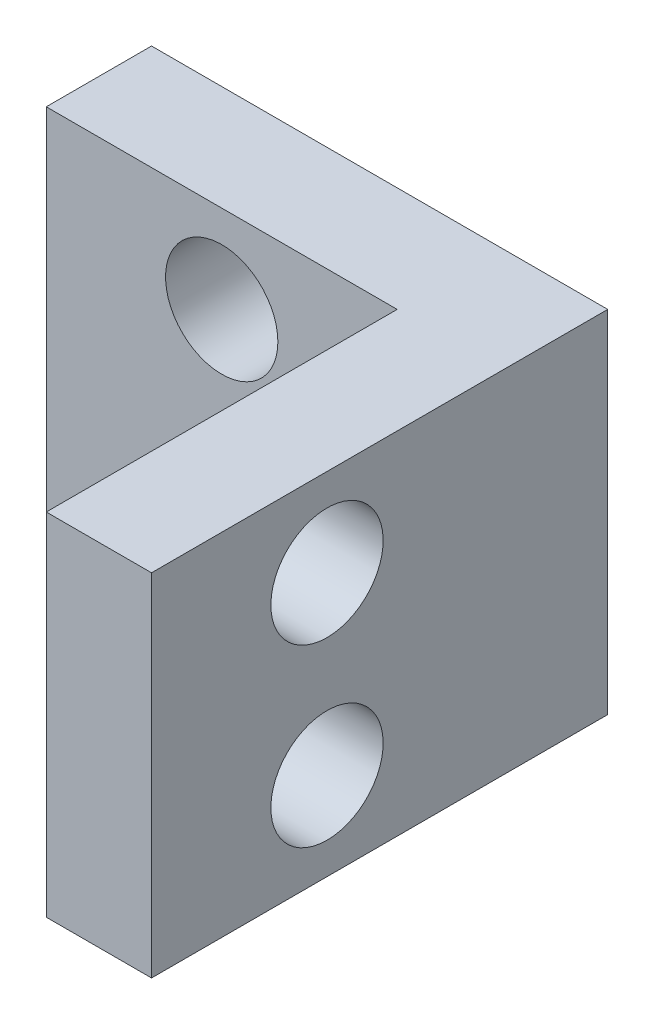
from build123d import *

# Parameters (mm, degrees)
SKETCH1_W           = 10
SKETCH1_H           = 10
BOSS_EXTRUDE1_DEPTH = 3
SKETCH2_W           = 13
SKETCH2_H           = 10
BOSS_EXTRUDE2_DEPTH = 3
SKETCH3_R           = 1.6
CUT_EXTRUDE1_DEPTH  = 4
SKETCH4_R           = 1.6
CUT_EXTRUDE2_DEPTH  = 4


with BuildPart() as part:
    # Sketch1 → Boss-Extrude1 (new body)
    with BuildSketch(Plane.XY):
        with Locations((5, -5)):
            Rectangle(SKETCH1_W, SKETCH1_H)
    extrude(amount=BOSS_EXTRUDE1_DEPTH)

    # Sketch2 → Boss-Extrude2 (add)
    with BuildSketch(Plane(origin=(10, 0, 0), x_dir=(0, 0, -1), z_dir=(1, 0, 0))):
        with Locations((-6.5, -5)):
            Rectangle(SKETCH2_W, SKETCH2_H)
    extrude(amount=BOSS_EXTRUDE2_DEPTH)

    # Sketch3 → Cut-Extrude1 (cut, through all)
    with BuildSketch(Plane.XY.offset(3)):
        with Locations((5, -2.5)):
            Circle(SKETCH3_R)
        with Locations((5, -7.5)):
            Circle(SKETCH3_R)
    extrude(amount=-CUT_EXTRUDE1_DEPTH, mode=Mode.SUBTRACT)

    # Sketch4 → Cut-Extrude2 (cut, through all)
    with BuildSketch(Plane.ZY.offset(-10)):
        with Locations((8, -2.5)):
            Circle(SKETCH4_R)
        with Locations((8, -7.5)):
            Circle(SKETCH4_R)
    extrude(amount=-CUT_EXTRUDE2_DEPTH, mode=Mode.SUBTRACT)


solid = part.part
